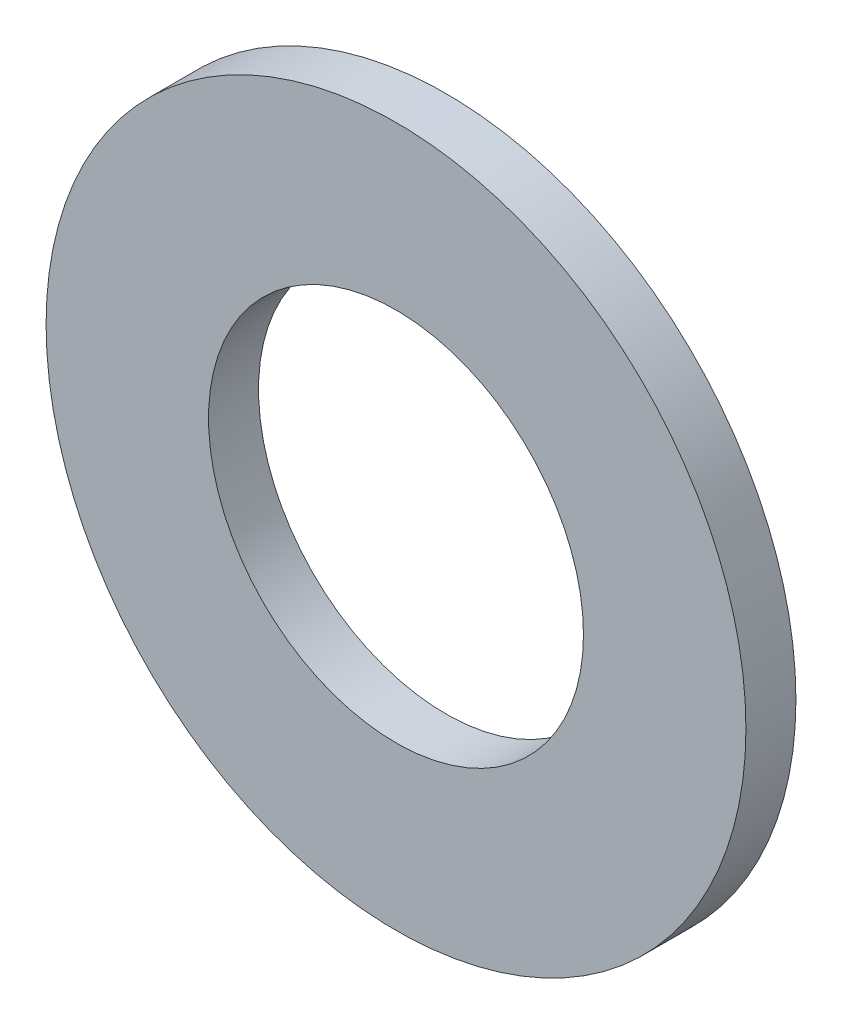
from build123d import *

# Parameters (mm, degrees)
SKETCH1_R           = 14
SKETCH1_R_2         = 7.5
BOSS_EXTRUDE1_DEPTH = 2


with BuildPart() as part:
    # Sketch1 → Boss-Extrude1 (new body)
    with BuildSketch(Plane.XY):
        Circle(SKETCH1_R)
        Circle(SKETCH1_R_2, mode=Mode.SUBTRACT)
    extrude(amount=BOSS_EXTRUDE1_DEPTH)


solid = part.part
